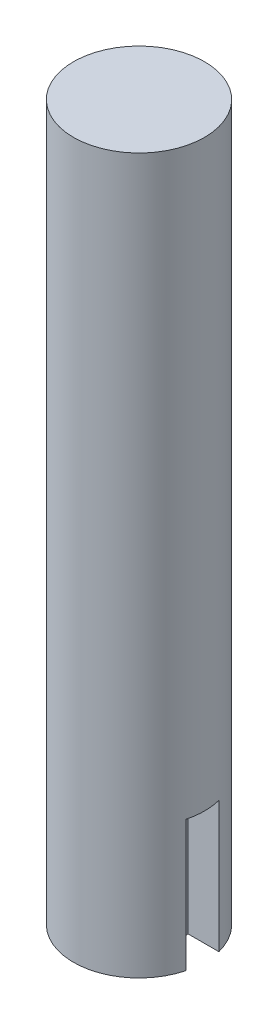
from build123d import *

# Parameters (mm, degrees)
SKETCH1_R           = 10
BOSS_EXTRUDE2_DEPTH = 109
SKETCH3_W           = 10
SKETCH3_H           = 5
CUT_EXTRUDE1_DEPTH  = 20


with BuildPart() as part:
    # Sketch1 → Boss-Extrude2 (new body)
    with BuildSketch(Plane(origin=(0, 0, 0), x_dir=(1, 0, 0), z_dir=(0, 1, 0))):
        Circle(SKETCH1_R)
    extrude(amount=BOSS_EXTRUDE2_DEPTH)

    # Sketch3 → Cut-Extrude1 (cut)
    with BuildSketch(Plane.XZ):
        with Locations((10, 0)):
            Rectangle(SKETCH3_W, SKETCH3_H)
    extrude(amount=-CUT_EXTRUDE1_DEPTH, mode=Mode.SUBTRACT)


solid = part.part
